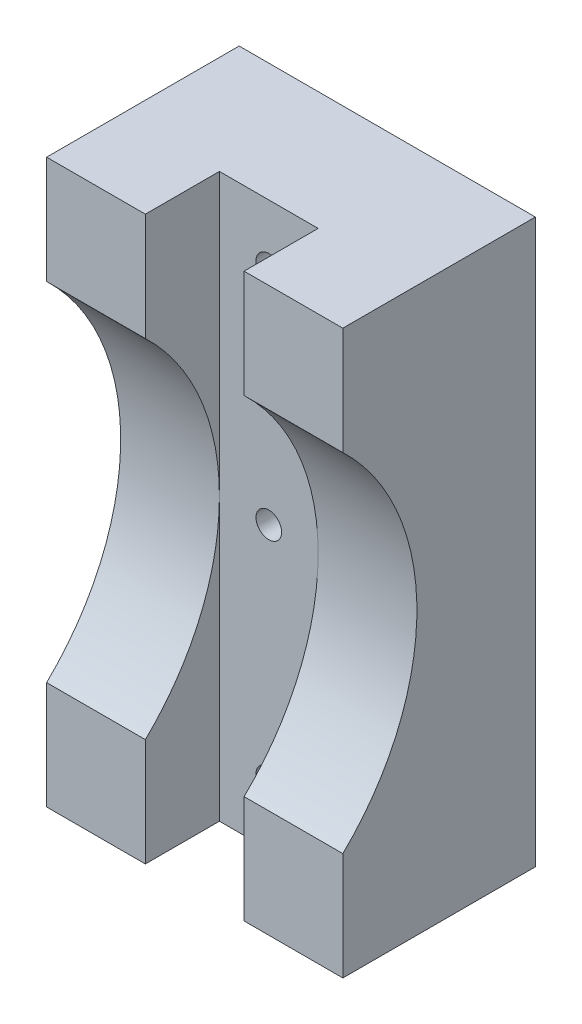
from build123d import *

# Parameters (mm, degrees)
BOSS_EXTRUDE1_DEPTH     = 10
SKETCH4_W               = 12
SKETCH4_H               = 57
BOSS_EXTRUDE2_DEPTH     = 10
SKETCH3_R               = 1.3
CUT_EXTRUDE1_DEPTH      = 1
CUT_EXTRUDE1_DEPTH_BACK = 20.5


with BuildPart() as part:
    # Sketch2 → Boss-Extrude1 (new body)
    with BuildSketch(Plane(origin=(0, 0, 0), x_dir=(0, 0, -1), z_dir=(1, 0, 0))):
        with BuildLine():
            Line((27, 28.5), (7.5, 28.5))
            Line((7.5, 28.5), (7.5, 17.589059099))
            ThreePointArc((7.5, 17.589059099), (15, 0), (7.5, -17.589059099))
            Line((7.5, -17.589059099), (7.5, -28.5))
            Line((7.5, -28.5), (27, -28.5))
            Line((27, -28.5), (27, 28.5))
        make_face()
    boss_extrude1 = extrude(amount=BOSS_EXTRUDE1_DEPTH)

    # Sketch4 → Boss-Extrude2 (add)
    with BuildSketch(Plane.ZY):
        with Locations((-21, 0)):
            Rectangle(SKETCH4_W, SKETCH4_H)
    extrude(amount=BOSS_EXTRUDE2_DEPTH)

    # Mirror1: Boss-Extrude1 across plane
    add(boss_extrude1.mirror(Plane.ZY.offset(5)))

    # Sketch3 → Cut-Extrude1 (cut, two sides)
    with BuildSketch(Plane(origin=(0, 0, -27), x_dir=(-1, 0, 0), z_dir=(0, 0, -1))) as cut_extrude1_sk:
        with Locations((5, -22.5)):
            Circle(SKETCH3_R)
        with Locations((5, 22.5)):
            Circle(SKETCH3_R)
        with Locations((5, 0)):
            Circle(SKETCH3_R)
    extrude(amount=CUT_EXTRUDE1_DEPTH, mode=Mode.SUBTRACT)
    extrude(cut_extrude1_sk.sketch, amount=-CUT_EXTRUDE1_DEPTH_BACK, mode=Mode.SUBTRACT)


solid = part.part
